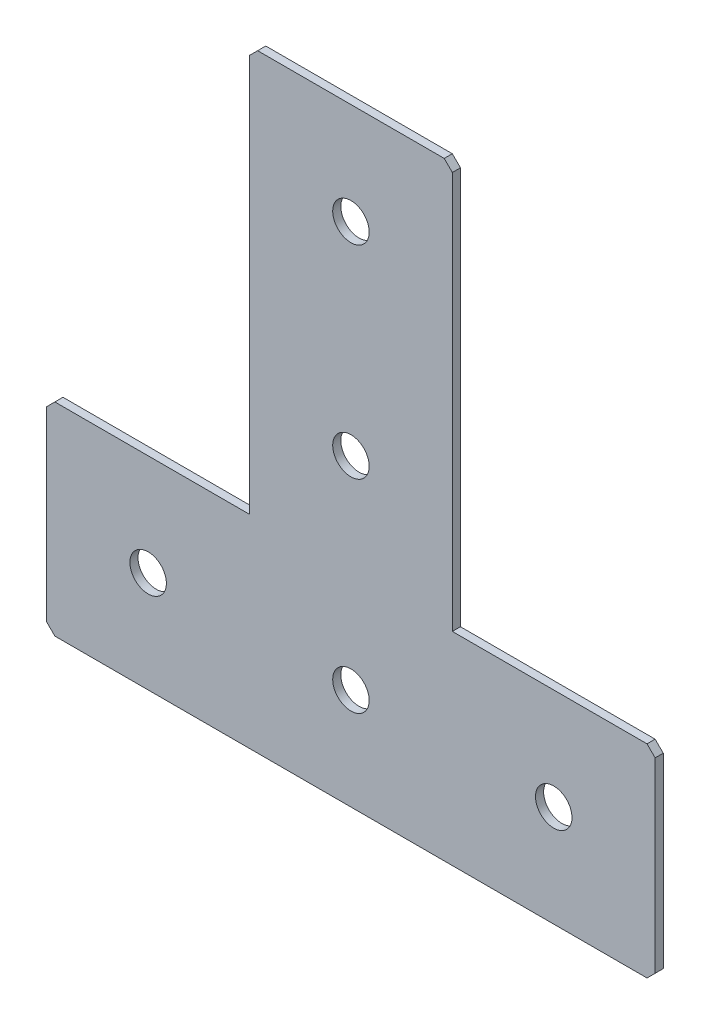
from build123d import *

# Parameters (mm, degrees)
EXTRUDE_1_DEPTH   = 2
HOLE_WIZARD_M81_D = 9
CHAMFER_1_SIZE    = 2


with BuildPart() as part:
    # Эскиз1 → Бобышка-Вытянуть1 (new body)
    with BuildSketch(Plane(origin=(0, 0, 0), x_dir=(1, 0, 0), z_dir=(0, 0, -1))):
        Polygon((-75, 150), (75, 150), (75, 100), (25, 100), (25, 0), (-25, 0), (-25, 100), (-75, 100), align=None)
    extrude(amount=EXTRUDE_1_DEPTH)

    # Отверстие с зазором M81 (through all)
    with Locations(Plane(origin=(0, 0, -2), x_dir=(1, 0, 0), z_dir=(0, 0, -1))):
        with Locations((0, 25), (0, 125), (-50, 125), (50, 125), (0, 75)):
            Hole(HOLE_WIZARD_M81_D / 2)

    # Фаска1
    chamfer_1_edges = [part.edges().sort_by_distance(p)[0] for p in [
        (-75, -100, -1),
        (-75, -150, -1),
        (75, -150, -1),
        (75, -100, -1),
        (25, 0, -1),
        (-25, 0, -1),
    ]]
    chamfer(chamfer_1_edges, length=CHAMFER_1_SIZE)


solid = part.part
